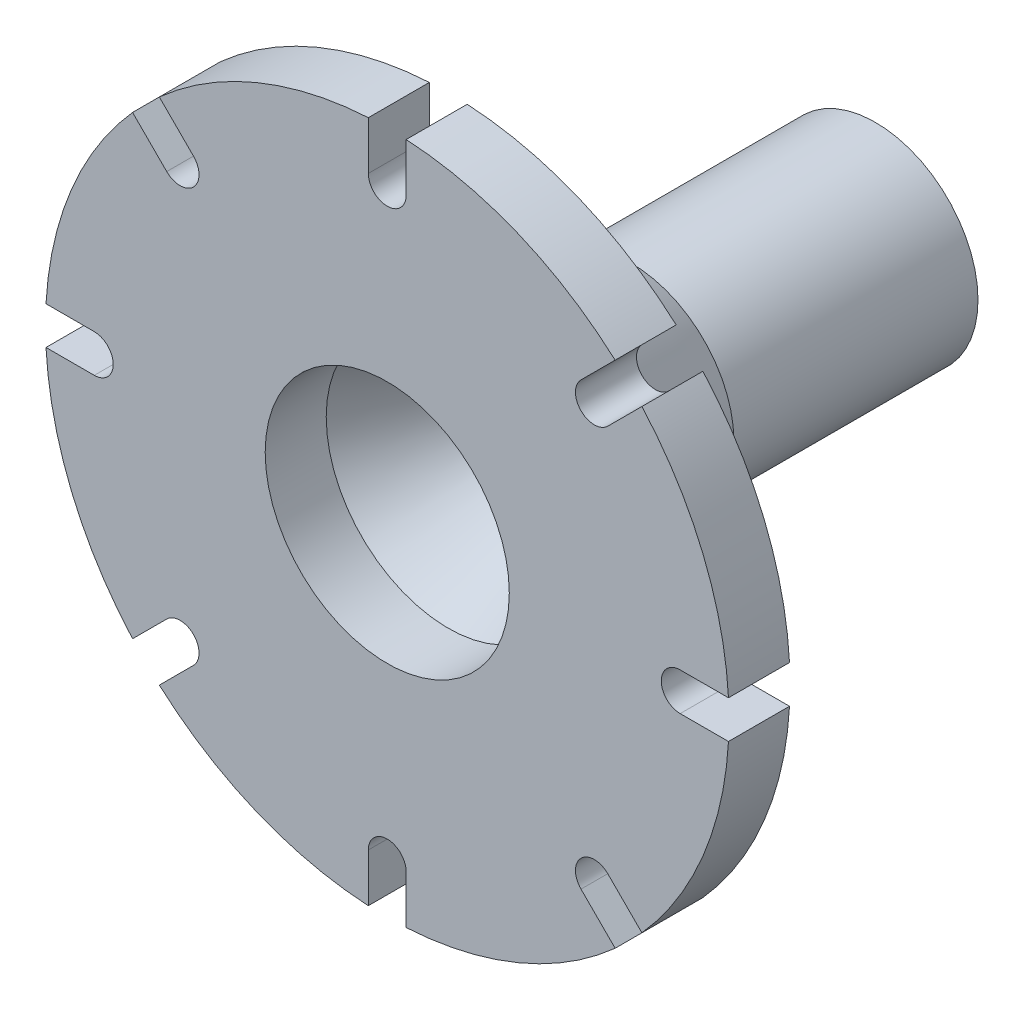
from build123d import *

# Parameters (mm, degrees)
SKETCH1_R           = 8.4
SKETCH1_R_2         = 3.4
BOSS_EXTRUDE1_DEPTH = 20
SKETCH2_R           = 8.4
SKETCH2_R_2         = 2.4
BOSS_EXTRUDE2_DEPTH = 1.5
SKETCH3_R           = 15
SKETCH3_R_2         = 10
BOSS_EXTRUDE3_DEPTH = 5
SKETCH5_R           = 28
SKETCH5_R_2         = 10
BOSS_EXTRUDE4_DEPTH = 5
CUT_EXTRUDE1_DEPTH  = 5


with BuildPart() as part:
    # Sketch1 → Boss-Extrude1 (new body)
    with BuildSketch(Plane.XY):
        Circle(SKETCH1_R)
        Circle(SKETCH1_R_2, mode=Mode.SUBTRACT)
    extrude(amount=BOSS_EXTRUDE1_DEPTH)

    # Sketch2 → Boss-Extrude2 (add)
    with BuildSketch(Plane.XY.offset(20)):
        Circle(SKETCH2_R)
        Circle(SKETCH2_R_2, mode=Mode.SUBTRACT)
    extrude(amount=-BOSS_EXTRUDE2_DEPTH)



with BuildPart() as body_2:
    # Sketch3 → Boss-Extrude3 (new body)
    with BuildSketch(Plane.XY.offset(35)):
        Circle(SKETCH3_R)
        Circle(SKETCH3_R_2, mode=Mode.SUBTRACT)
    extrude(amount=BOSS_EXTRUDE3_DEPTH)


with BuildPart() as part_1:
    add(part.part)

    add(body_2.part)  # Revolve1 merges body 2
    # Sketch4 → Revolve1 (revolve)
    with BuildSketch(Plane(origin=(0, 0, 0), x_dir=(1, 0, 0), z_dir=(0, 1, 0))):
        Polygon((-8.4, -20), (-15, -35), (-10, -35), (-2.4, -20), align=None)
    revolve(axis=Axis((0, 0, 20), (0, 0, 1)))

    # Sketch5 → Boss-Extrude4 (add)
    with BuildSketch(Plane.XY.offset(40)):
        Circle(SKETCH5_R)
        Circle(SKETCH5_R_2, mode=Mode.SUBTRACT)
    extrude(amount=-BOSS_EXTRUDE4_DEPTH)

    # Sketch6 → Cut-Extrude1 (cut)
    with BuildSketch(Plane(origin=(0, 0, 35), x_dir=(-1, 0, 0), z_dir=(0, 0, -1))):
        with BuildLine():
            Line((-1.55, 24), (-1.55, 29))
            Line((-1.55, 29), (1.55, 29))
            Line((1.55, 29), (1.55, 24))
            ThreePointArc((1.55, 24), (0, 22.45), (-1.55, 24))
        make_face()
        with BuildLine():
            Line((21.602112165, 19.410081144), (18.066578259, 15.874547238))
            ThreePointArc((18.066578259, 15.874547238), (15.874547238, 15.874547238), (15.874547238, 18.066578259))
            Line((15.874547238, 18.066578259), (19.410081144, 21.602112165))
            Line((19.410081144, 21.602112165), (21.602112165, 19.410081144))
        make_face()
        with BuildLine():
            Line((29, -1.55), (24, -1.55))
            ThreePointArc((24, -1.55), (22.45, 0), (24, 1.55))
            Line((24, 1.55), (29, 1.55))
            Line((29, 1.55), (29, -1.55))
        make_face()
        with BuildLine():
            Line((19.410081144, -21.602112165), (15.874547238, -18.066578259))
            ThreePointArc((15.874547238, -18.066578259), (15.874547238, -15.874547238), (18.066578259, -15.874547238))
            Line((18.066578259, -15.874547238), (21.602112165, -19.410081144))
            Line((21.602112165, -19.410081144), (19.410081144, -21.602112165))
        make_face()
        with BuildLine():
            Line((-1.55, -29), (-1.55, -24))
            ThreePointArc((-1.55, -24), (0, -22.45), (1.55, -24))
            Line((1.55, -24), (1.55, -29))
            Line((1.55, -29), (-1.55, -29))
        make_face()
        with BuildLine():
            Line((-21.602112165, -19.410081144), (-18.066578259, -15.874547238))
            ThreePointArc((-18.066578259, -15.874547238), (-15.874547238, -15.874547238), (-15.874547238, -18.066578259))
            Line((-15.874547238, -18.066578259), (-19.410081144, -21.602112165))
            Line((-19.410081144, -21.602112165), (-21.602112165, -19.410081144))
        make_face()
        with BuildLine():
            Line((-29, 1.55), (-24, 1.55))
            ThreePointArc((-24, 1.55), (-22.45, 0), (-24, -1.55))
            Line((-24, -1.55), (-29, -1.55))
            Line((-29, -1.55), (-29, 1.55))
        make_face()
        with BuildLine():
            Line((-19.410081144, 21.602112165), (-15.874547238, 18.066578259))
            ThreePointArc((-15.874547238, 18.066578259), (-15.874547238, 15.874547238), (-18.066578259, 15.874547238))
            Line((-18.066578259, 15.874547238), (-21.602112165, 19.410081144))
            Line((-21.602112165, 19.410081144), (-19.410081144, 21.602112165))
        make_face()
    extrude(amount=-CUT_EXTRUDE1_DEPTH, mode=Mode.SUBTRACT)


solid = part_1.part
